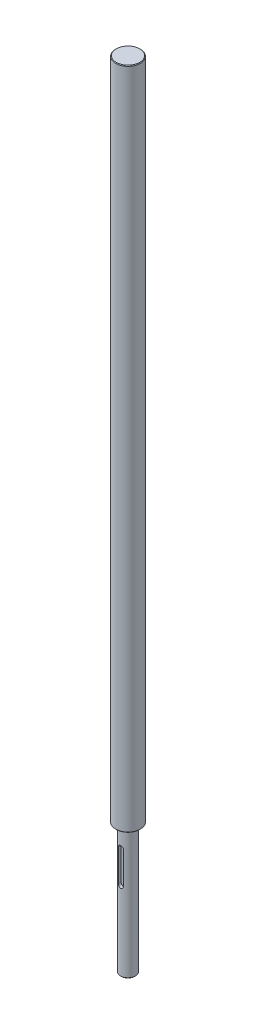
from build123d import *

# Parameters (mm, degrees)
SKIZZE1_R                       = 10
AUFSATZ_LINEAR_AUSTRAGEN1_DEPTH = 538
SKIZZE2_R                       = 6
AUFSATZ_LINEAR_AUSTRAGEN2_DEPTH = 105
FASE1_SIZE                      = 0.5
CUT_EXTRUDE1_DEPTH              = 2.5


with BuildPart() as part:
    # Skizze1 → Aufsatz-Linear austragen1 (new body)
    with BuildSketch(Plane(origin=(0, 0, 0), x_dir=(1, 0, 0), z_dir=(0, 1, 0))):
        with Locations(Location((0, 0, 0), (0, 0, 270))):  # turned: the seam where the file's is
            Circle(SKIZZE1_R)
    extrude(amount=AUFSATZ_LINEAR_AUSTRAGEN1_DEPTH)

    # Skizze2 → Aufsatz-Linear austragen2 (add)
    with BuildSketch(Plane.XZ):
        with Locations(Location((0, 0, 0), (0, 0, 90))):  # turned: the seam where the file's is
            Circle(SKIZZE2_R)
    extrude(amount=AUFSATZ_LINEAR_AUSTRAGEN2_DEPTH)

    # Fase1
    fase1_edges = [part.edges().sort_by_distance(p)[0] for p in [
        (0, 0, -10),
        (0, 538, -10),
        (0, -105, -6),
    ]]
    chamfer(fase1_edges, length=FASE1_SIZE)

    # Sketch3 → Cut-Extrude1 (cut)
    with BuildSketch(Plane(origin=(1.706808785, -105, 6), x_dir=(0, -1, 0), z_dir=(0, 0, -1))):
        with BuildLine():
            Line((-64, 3.706808785), (-90, 3.706808785))
            ThreePointArc((-90, 3.706808785), (-92, 1.706808785), (-90, -0.293191215))
            Line((-90, -0.293191215), (-64, -0.293191215))
            ThreePointArc((-64, -0.293191215), (-62, 1.706808785), (-64, 3.706808785))
        make_face()
    extrude(amount=CUT_EXTRUDE1_DEPTH, mode=Mode.SUBTRACT)


solid = part.part
